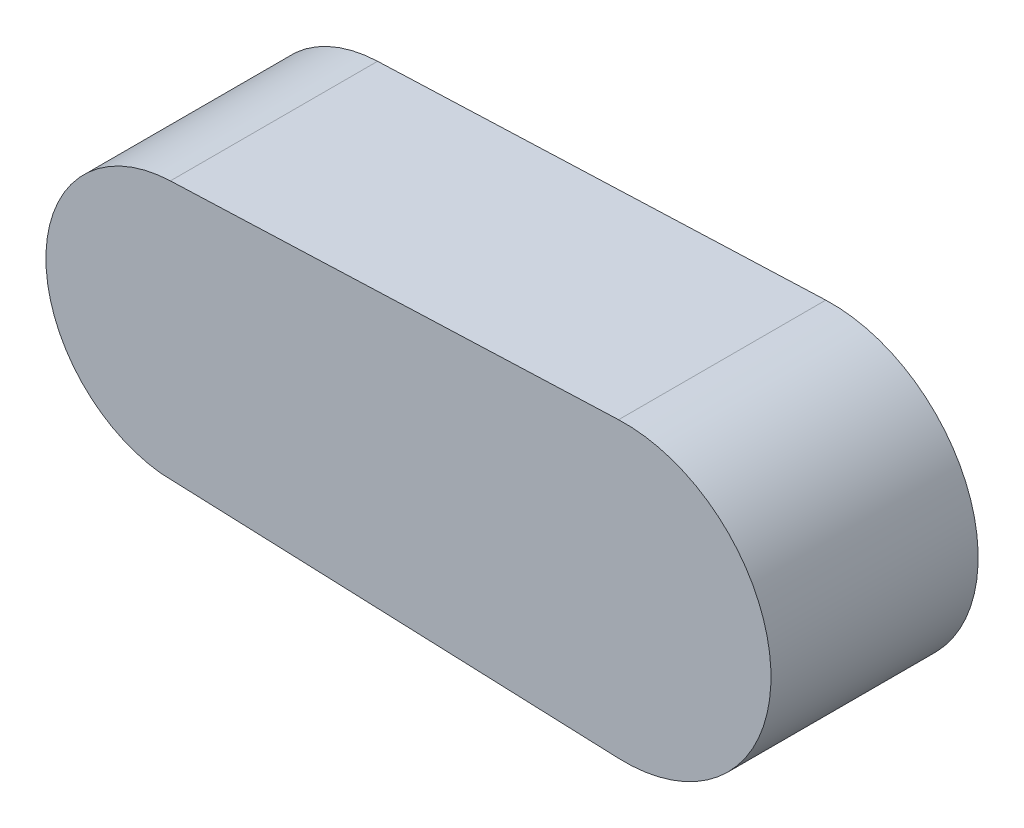
from build123d import *

# Parameters (mm, degrees)
EXTRUDE1_DEPTH = 120


with BuildPart() as part:
    # Sketch1 → Extrude1 (new body)
    with BuildSketch(Plane.XY):
        with BuildLine():
            Line((-137.884615385, 74.944506097), (121.730769231, 84.93710691))
            ThreePointArc((121.730769231, 84.93710691), (209.999993587, -0.033019104), (121.664780878, -84.934541345))
            Line((121.664780878, -84.934541345), (-143.429437146, -74.524791777))
            ThreePointArc((-143.429437146, -74.524791777), (-209.948446934, 2.780342087), (-137.884615385, 74.944506097))
        make_face()
    extrude(amount=EXTRUDE1_DEPTH)


solid = part.part
